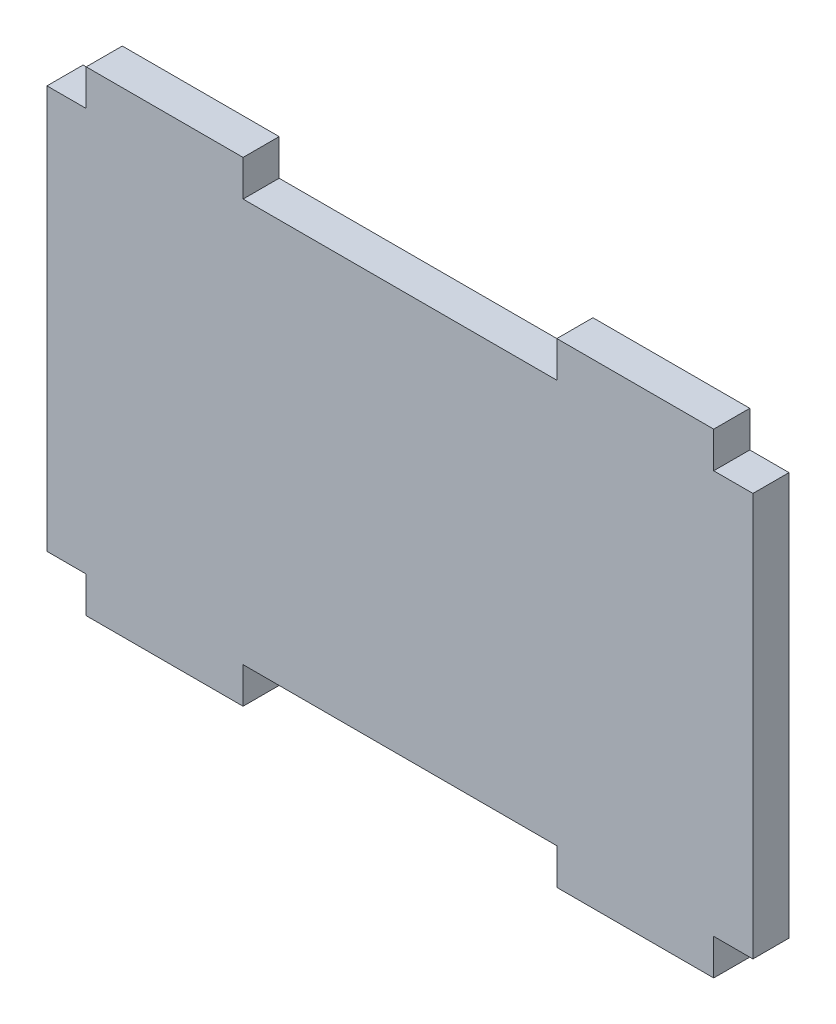
from build123d import *

# Parameters (mm, degrees)
BOSS_EXTRUDE1_DEPTH = 2.3


with BuildPart() as part:
    # Sketch1 → Boss-Extrude1 (new body)
    with BuildSketch(Plane.XY.offset(2.9972)):
        Polygon((0, 2.3), (0, 28), (2.5, 28), (2.5, 30.3), (12.5, 30.3), (12.5, 28), (32.5, 28), (32.5, 30.3), (42.5, 30.3), (42.5, 28), (45, 28), (45, 2.3), (42.5, 2.3), (42.5, 0), (32.5, 0), (32.5, 2.3), (22.5, 2.3), (12.5, 2.3), (12.5, 0), (2.5, 0), (2.5, 2.3), align=None)
    extrude(amount=-BOSS_EXTRUDE1_DEPTH)


solid = part.part
